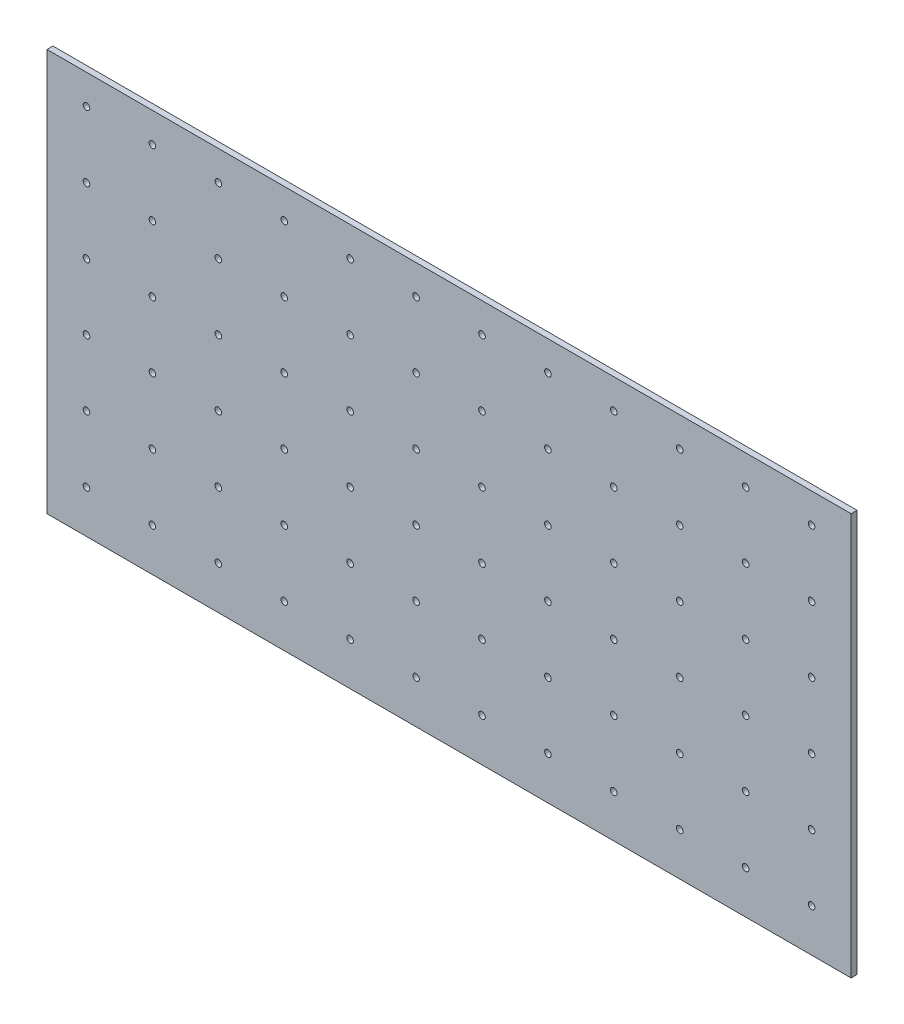
from build123d import *

# Parameters (mm, degrees)
SKETCH1_W           = 2440
SKETCH1_H           = 1220
SKETCH1_R           = 10
BOSS_EXTRUDE2_DEPTH = 18


with BuildPart() as part:
    # Sketch1 → Boss-Extrude2 (new body)
    with BuildSketch(Plane.XY):
        with Locations((-990.892018779, -8.591549296)):
            Rectangle(SKETCH1_W, SKETCH1_H)
        with Locations((-2090.892018779, 511.408450704)):
            Circle(SKETCH1_R, mode=Mode.SUBTRACT)
        with Locations((-1890.892018779, 511.408450704)):
            Circle(SKETCH1_R, mode=Mode.SUBTRACT)
        with Locations((-1690.892018779, 511.408450704)):
            Circle(SKETCH1_R, mode=Mode.SUBTRACT)
        with Locations((-1490.892018779, 511.408450704)):
            Circle(SKETCH1_R, mode=Mode.SUBTRACT)
        with Locations((-2090.892018779, 311.408450704)):
            Circle(SKETCH1_R, mode=Mode.SUBTRACT)
        with Locations((-1890.892018779, 311.408450704)):
            Circle(SKETCH1_R, mode=Mode.SUBTRACT)
        with Locations((-1690.892018779, 311.408450704)):
            Circle(SKETCH1_R, mode=Mode.SUBTRACT)
        with Locations((-1490.892018779, 311.408450704)):
            Circle(SKETCH1_R, mode=Mode.SUBTRACT)
        with Locations((-1290.892018779, 511.408450704)):
            Circle(SKETCH1_R, mode=Mode.SUBTRACT)
        with Locations((-1290.892018779, 311.408450704)):
            Circle(SKETCH1_R, mode=Mode.SUBTRACT)
        with Locations((-1090.892018779, 511.408450704)):
            Circle(SKETCH1_R, mode=Mode.SUBTRACT)
        with Locations((-1090.892018779, 311.408450704)):
            Circle(SKETCH1_R, mode=Mode.SUBTRACT)
        with Locations((-890.892018779, 511.408450704)):
            Circle(SKETCH1_R, mode=Mode.SUBTRACT)
        with Locations((-890.892018779, 311.408450704)):
            Circle(SKETCH1_R, mode=Mode.SUBTRACT)
        with Locations((-890.892018779, 111.408450704)):
            Circle(SKETCH1_R, mode=Mode.SUBTRACT)
        with Locations((-1090.892018779, 111.408450704)):
            Circle(SKETCH1_R, mode=Mode.SUBTRACT)
        with Locations((-1290.892018779, 111.408450704)):
            Circle(SKETCH1_R, mode=Mode.SUBTRACT)
        with Locations((-1490.892018779, 111.408450704)):
            Circle(SKETCH1_R, mode=Mode.SUBTRACT)
        with Locations((-1690.892018779, 111.408450704)):
            Circle(SKETCH1_R, mode=Mode.SUBTRACT)
        with Locations((-1890.892018779, 111.408450704)):
            Circle(SKETCH1_R, mode=Mode.SUBTRACT)
        with Locations((-2090.892018779, 111.408450704)):
            Circle(SKETCH1_R, mode=Mode.SUBTRACT)
        with Locations((-2090.892018779, -88.591549296)):
            Circle(SKETCH1_R, mode=Mode.SUBTRACT)
        with Locations((-1890.892018779, -88.591549296)):
            Circle(SKETCH1_R, mode=Mode.SUBTRACT)
        with Locations((-1690.892018779, -88.591549296)):
            Circle(SKETCH1_R, mode=Mode.SUBTRACT)
        with Locations((-1490.892018779, -88.591549296)):
            Circle(SKETCH1_R, mode=Mode.SUBTRACT)
        with Locations((-1290.892018779, -88.591549296)):
            Circle(SKETCH1_R, mode=Mode.SUBTRACT)
        with Locations((-1090.892018779, -88.591549296)):
            Circle(SKETCH1_R, mode=Mode.SUBTRACT)
        with Locations((-890.892018779, -88.591549296)):
            Circle(SKETCH1_R, mode=Mode.SUBTRACT)
        with Locations((-690.892018779, -88.591549296)):
            Circle(SKETCH1_R, mode=Mode.SUBTRACT)
        with Locations((-490.892018779, -88.591549296)):
            Circle(SKETCH1_R, mode=Mode.SUBTRACT)
        with Locations((-490.892018779, 111.408450704)):
            Circle(SKETCH1_R, mode=Mode.SUBTRACT)
        with Locations((-490.892018779, 311.408450704)):
            Circle(SKETCH1_R, mode=Mode.SUBTRACT)
        with Locations((-490.892018779, 511.408450704)):
            Circle(SKETCH1_R, mode=Mode.SUBTRACT)
        with Locations((-690.892018779, 511.408450704)):
            Circle(SKETCH1_R, mode=Mode.SUBTRACT)
        with Locations((-690.892018779, 311.408450704)):
            Circle(SKETCH1_R, mode=Mode.SUBTRACT)
        with Locations((-690.892018779, 111.408450704)):
            Circle(SKETCH1_R, mode=Mode.SUBTRACT)
        with Locations((-490.892018779, -288.591549296)):
            Circle(SKETCH1_R, mode=Mode.SUBTRACT)
        with Locations((-690.892018779, -288.591549296)):
            Circle(SKETCH1_R, mode=Mode.SUBTRACT)
        with Locations((-890.892018779, -288.591549296)):
            Circle(SKETCH1_R, mode=Mode.SUBTRACT)
        with Locations((-1090.892018779, -288.591549296)):
            Circle(SKETCH1_R, mode=Mode.SUBTRACT)
        with Locations((-1290.892018779, -288.591549296)):
            Circle(SKETCH1_R, mode=Mode.SUBTRACT)
        with Locations((-1490.892018779, -288.591549296)):
            Circle(SKETCH1_R, mode=Mode.SUBTRACT)
        with Locations((-1690.892018779, -288.591549296)):
            Circle(SKETCH1_R, mode=Mode.SUBTRACT)
        with Locations((-1890.892018779, -288.591549296)):
            Circle(SKETCH1_R, mode=Mode.SUBTRACT)
        with Locations((-2090.892018779, -288.591549296)):
            Circle(SKETCH1_R, mode=Mode.SUBTRACT)
        with Locations((-2090.892018779, -488.591549296)):
            Circle(SKETCH1_R, mode=Mode.SUBTRACT)
        with Locations((-1890.892018779, -488.591549296)):
            Circle(SKETCH1_R, mode=Mode.SUBTRACT)
        with Locations((-1690.892018779, -488.591549296)):
            Circle(SKETCH1_R, mode=Mode.SUBTRACT)
        with Locations((-1490.892018779, -488.591549296)):
            Circle(SKETCH1_R, mode=Mode.SUBTRACT)
        with Locations((-1290.892018779, -488.591549296)):
            Circle(SKETCH1_R, mode=Mode.SUBTRACT)
        with Locations((-1090.892018779, -488.591549296)):
            Circle(SKETCH1_R, mode=Mode.SUBTRACT)
        with Locations((-890.892018779, -488.591549296)):
            Circle(SKETCH1_R, mode=Mode.SUBTRACT)
        with Locations((-690.892018779, -488.591549296)):
            Circle(SKETCH1_R, mode=Mode.SUBTRACT)
        with Locations((-490.892018779, -488.591549296)):
            Circle(SKETCH1_R, mode=Mode.SUBTRACT)
        with Locations((-290.892018779, 511.408450704)):
            Circle(SKETCH1_R, mode=Mode.SUBTRACT)
        with Locations((-290.892018779, 311.408450704)):
            Circle(SKETCH1_R, mode=Mode.SUBTRACT)
        with Locations((-290.892018779, 111.408450704)):
            Circle(SKETCH1_R, mode=Mode.SUBTRACT)
        with Locations((-290.892018779, -88.591549296)):
            Circle(SKETCH1_R, mode=Mode.SUBTRACT)
        with Locations((-290.892018779, -288.591549296)):
            Circle(SKETCH1_R, mode=Mode.SUBTRACT)
        with Locations((-290.892018779, -488.591549296)):
            Circle(SKETCH1_R, mode=Mode.SUBTRACT)
        with Locations((-90.892018779, 511.408450704)):
            Circle(SKETCH1_R, mode=Mode.SUBTRACT)
        with Locations((-90.892018779, 311.408450704)):
            Circle(SKETCH1_R, mode=Mode.SUBTRACT)
        with Locations((-90.892018779, 111.408450704)):
            Circle(SKETCH1_R, mode=Mode.SUBTRACT)
        with Locations((-90.892018779, -88.591549296)):
            Circle(SKETCH1_R, mode=Mode.SUBTRACT)
        with Locations((-90.892018779, -288.591549296)):
            Circle(SKETCH1_R, mode=Mode.SUBTRACT)
        with Locations((-90.892018779, -488.591549296)):
            Circle(SKETCH1_R, mode=Mode.SUBTRACT)
        with Locations((109.107981221, -488.591549296)):
            Circle(SKETCH1_R, mode=Mode.SUBTRACT)
        with Locations((109.107981221, -288.591549296)):
            Circle(SKETCH1_R, mode=Mode.SUBTRACT)
        with Locations((109.107981221, -88.591549296)):
            Circle(SKETCH1_R, mode=Mode.SUBTRACT)
        with Locations((109.107981221, 111.408450704)):
            Circle(SKETCH1_R, mode=Mode.SUBTRACT)
        with Locations((109.107981221, 311.408450704)):
            Circle(SKETCH1_R, mode=Mode.SUBTRACT)
        with Locations((109.107981221, 511.408450704)):
            Circle(SKETCH1_R, mode=Mode.SUBTRACT)
    extrude(amount=BOSS_EXTRUDE2_DEPTH)


solid = part.part
